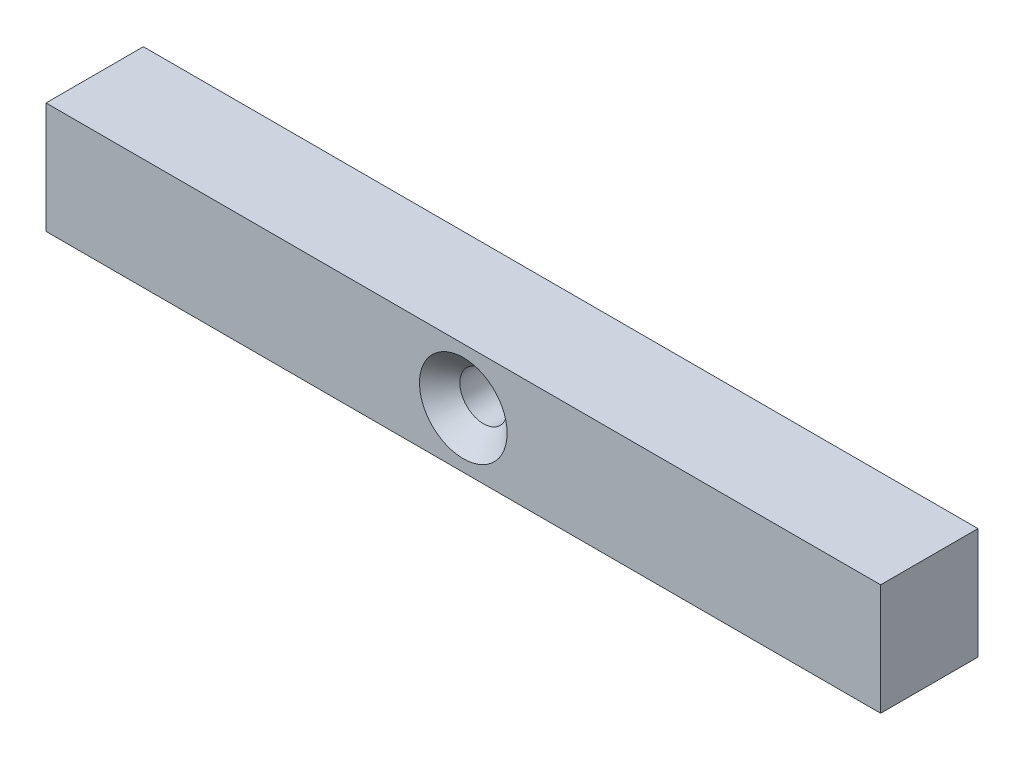
from build123d import *

# Parameters (mm, degrees)
SKETCH1_W                                           = 60
SKETCH1_H                                           = 8
BOSS_EXTRUDE1_DEPTH                                 = 7
CSK_FOR_M3_COUNTERSUNK_FLAT_HEAD_SCREW1_D           = 3.4
CSK_FOR_M3_COUNTERSUNK_FLAT_HEAD_SCREW1_CSINK_D     = 6.3
CSK_FOR_M3_COUNTERSUNK_FLAT_HEAD_SCREW1_CSINK_ANGLE = 90


with BuildPart() as part:
    # Sketch1 → Boss-Extrude1 (new body)
    with BuildSketch(Plane.XY):
        Rectangle(SKETCH1_W, SKETCH1_H)
    extrude(amount=BOSS_EXTRUDE1_DEPTH)

    # CSK for M3 Countersunk Flat Head Screw1 (through all)
    with Locations(Plane.XY.offset(7)):
        with Locations((0, 0)):
            CounterSinkHole(CSK_FOR_M3_COUNTERSUNK_FLAT_HEAD_SCREW1_D / 2, CSK_FOR_M3_COUNTERSUNK_FLAT_HEAD_SCREW1_CSINK_D / 2, counter_sink_angle=CSK_FOR_M3_COUNTERSUNK_FLAT_HEAD_SCREW1_CSINK_ANGLE)


solid = part.part
